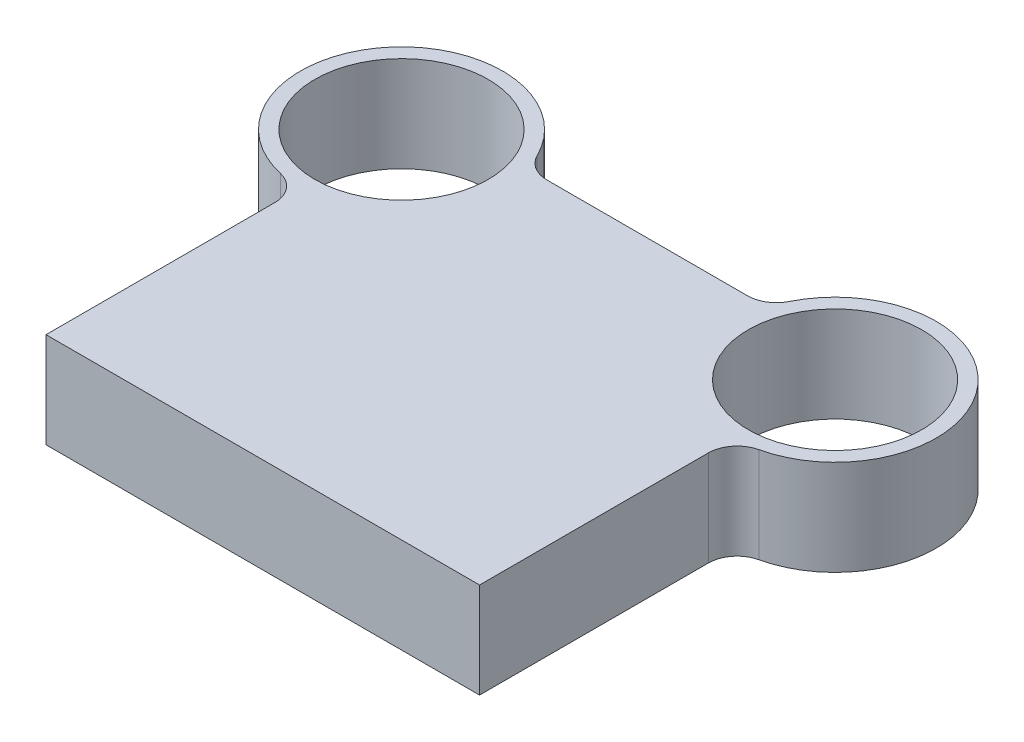
from build123d import *

# Parameters (mm, degrees)
SKETCH1_R           = 30
BOSS_EXTRUDE1_DEPTH = 33
FILLET1_R           = 10


with BuildPart() as part:
    # Sketch1 → Boss-Extrude1 (new body)
    with BuildSketch(Plane(origin=(0, 0, 0), x_dir=(1, 0, 0), z_dir=(0, 1, 0))):
        with BuildLine():
            Line((75, 0), (-75, 0))
            Line((-75, 0), (-75, 88))
            ThreePointArc((-75, 88), (-103.062430401, 143.916500663), (-41.458980338, 133))
            Line((-41.458980338, 133), (41.458980338, 133))
            ThreePointArc((41.458980338, 133), (103.062430401, 143.916500663), (75, 88))
            Line((75, 88), (75, 0))
        make_face()
        with Locations((-75, 123)):
            Circle(SKETCH1_R, mode=Mode.SUBTRACT)
        with Locations((75, 123)):
            Circle(SKETCH1_R, mode=Mode.SUBTRACT)
    extrude(amount=BOSS_EXTRUDE1_DEPTH)

    # Fillet1
    fillet1_edges = [part.edges().sort_by_distance(p)[0] for p in [
        (-75, 16.5, -88),
        (-41.458980338, 16.5, -133),
        (41.458980338, 16.5, -133),
        (75, 16.5, -88),
    ]]
    fillet(fillet1_edges, radius=FILLET1_R)


solid = part.part
